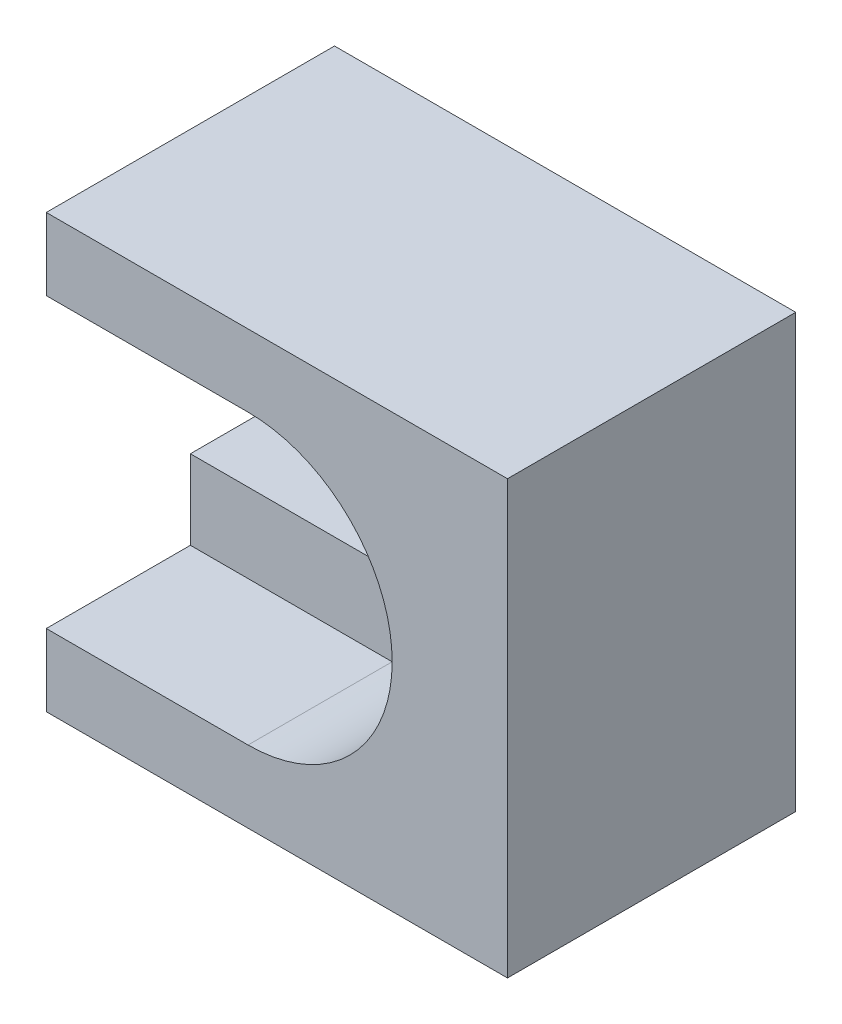
from build123d import *

# Parameters (mm, degrees)
SKIZZE1_W                       = 16
SKIZZE1_H                       = 15
AUFSATZ_LINEAR_AUSTRAGEN1_DEPTH = 10
SCHNITT_LINEAR_AUSTRAGEN1_DEPTH = 5
SCHNITT_LINEAR_AUSTRAGEN2_DEPTH = 6


with BuildPart() as part:
    # Skizze1 → Aufsatz-Linear austragen1 (new body)
    with BuildSketch(Plane.XY):
        with Locations((8, 7.5)):
            Rectangle(SKIZZE1_W, SKIZZE1_H)
    extrude(amount=AUFSATZ_LINEAR_AUSTRAGEN1_DEPTH)

    # Skizze2 → Schnitt-Linear austragen1 (cut)
    with BuildSketch(Plane.XY.offset(10)):
        with BuildLine():
            Line((0, 12.5), (7, 12.5))
            ThreePointArc((7, 12.5), (12, 7.5), (7, 2.5))
            Line((7, 2.5), (0, 2.5))
            ThreePointArc((0, 2.5), (-5, 7.5), (0, 12.5))
        make_face()
    extrude(amount=-SCHNITT_LINEAR_AUSTRAGEN1_DEPTH, mode=Mode.SUBTRACT)

    # Skizze3 → Schnitt-Linear austragen2 (cut, through all)
    with BuildSketch(Plane.XY.offset(5)):
        with BuildLine():
            Line((0, 9.75), (7, 9.75))
            ThreePointArc((7, 9.75), (9.25, 7.5), (7, 5.25))
            Line((7, 5.25), (0, 5.25))
            ThreePointArc((0, 5.25), (-2.25, 7.5), (0, 9.75))
        make_face()
    extrude(amount=-SCHNITT_LINEAR_AUSTRAGEN2_DEPTH, mode=Mode.SUBTRACT)


solid = part.part
